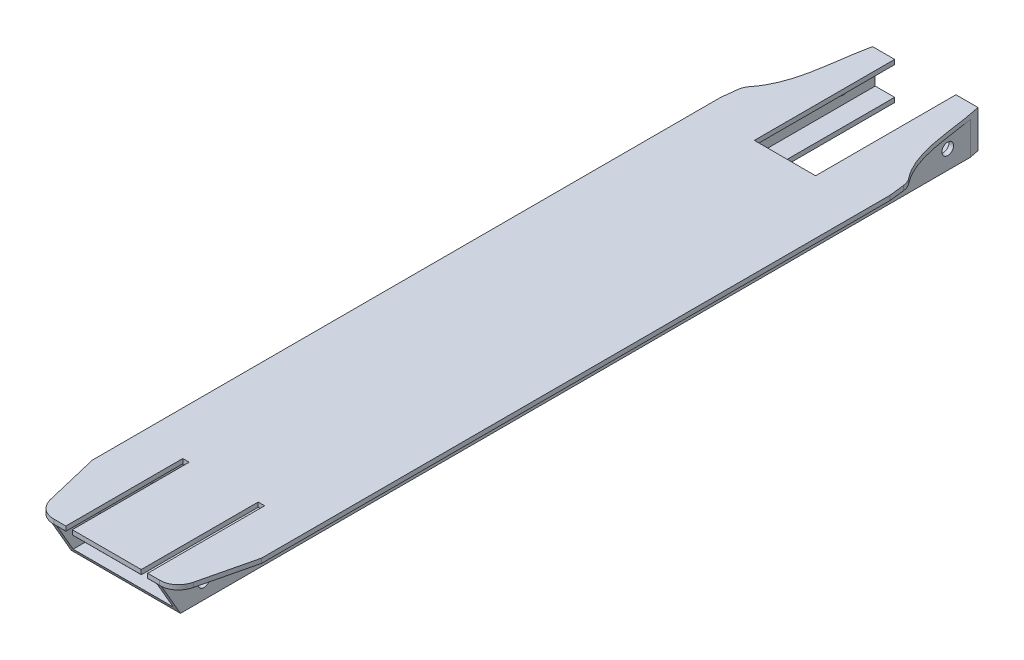
from build123d import *

# Parameters (mm, degrees)
SKETCH1_W               = 92.0242
SKETCH1_H               = 20.32
BOSS_EXTRUDE1_DEPTH     = 444.5
SKETCH2_W               = 54.356
SKETCH2_H               = 15.3416
SKETCH2_W_2             = 16.3449
SKETCH2_H_2             = 17.8308
CUT_EXTRUDE1_DEPTH      = 445.5
SKETCH3_W               = 33.274
SKETCH3_H               = 76.2
CUT_EXTRUDE2_DEPTH      = 21.32
SKETCH4_W               = 3.5052
SKETCH4_H               = 63.5
CUT_EXTRUDE3_DEPTH      = 12.7
CUT_EXTRUDE5_DEPTH      = 76.6793001
SKETCH6_R               = 3.175
CUT_EXTRUDE6_DEPTH      = 76.6793001
SKETCH7_R               = 1.764906423
CUT_EXTRUDE7_DEPTH      = 76.6793001
SKETCH9_R               = 3.175
CUT_EXTRUDE8_DEPTH      = 47.0121001
CUT_EXTRUDE8_DEPTH_BACK = 47.0121001


with BuildPart() as part:
    # Sketch1 → Boss-Extrude1 (new body)
    with BuildSketch(Plane.XY):
        with Locations((0, -10.16)):
            Rectangle(SKETCH1_W, SKETCH1_H)
    extrude(amount=-BOSS_EXTRUDE1_DEPTH)

    # Sketch2 → Cut-Extrude1 (cut, through all)
    with BuildSketch(Plane.XY):
        with Locations((0, -10.16)):
            Rectangle(SKETCH2_W, SKETCH2_H)
        with Locations((37.83965, -11.4046)):
            Rectangle(SKETCH2_W_2, SKETCH2_H_2)
        with Locations((-37.83965, -11.4046)):
            Rectangle(SKETCH2_W_2, SKETCH2_H_2)
    extrude(amount=-CUT_EXTRUDE1_DEPTH, mode=Mode.SUBTRACT)

    # Sketch3 → Cut-Extrude2 (cut, through all)
    with BuildSketch(Plane(origin=(0, 0, 0), x_dir=(1, 0, 0), z_dir=(0, 1, 0))):
        with BuildLine():
            Line((-46.0121, 0), (-28.575, 0))
            add(Edge.make_bspline(
                [(-28.575, 0), (-35.717859011, 0), (-38.245794082, 5.707856621), (-38.842625262, 8.197153509)],
                knots=[0, 0, 0, 0, 1, 1, 1, 1], degree=3))
            Line((-38.842625262, 8.197153509), (-46.0121, 38.1))
            Line((-46.0121, 38.1), (-46.0121, 0))
        make_face()
        with BuildLine():
            add(Edge.make_bspline(
                [(28.575, 0), (35.717859011, 0), (38.245794082, 5.707856621), (38.842625262, 8.197153509)],
                knots=[0, 0, 0, 0, 1, 1, 1, 1], degree=3))
            Line((28.575, 0), (46.0121, 0))
            Line((46.0121, 0), (46.0121, 38.1))
            Line((46.0121, 38.1), (38.842625262, 8.197153509))
        make_face()
        with BuildLine():
            Line((46.0121, 444.5), (28.6258, 444.5))
            add(Edge.make_bspline(
                [(28.6258, 444.5), (32.693382337, 426.337896511), (31.854875968, 406.755772808), (43.153705429, 392.326383256)],
                knots=[0, 0, 0, 0, 0.951264786, 0.951264786, 0.951264786, 0.951264786], degree=3))
            ThreePointArc((43.153705429, 392.326383256), (44.408270339, 390.171508327), (45.032534863, 387.757442695))
            Line((45.032534863, 387.757442695), (46.0121, 379.348138392))
            Line((46.0121, 379.348138392), (46.0121, 444.5))
        make_face()
        with Locations((0, 406.4)):
            Rectangle(SKETCH3_W, SKETCH3_H)
        with BuildLine():
            add(Edge.make_bspline(
                [(-28.6258, 444.5), (-32.693382337, 426.337896511), (-31.854875968, 406.755772808), (-43.153705429, 392.326383256)],
                knots=[0, 0, 0, 0, 0.951264786, 0.951264786, 0.951264786, 0.951264786], degree=3))
            Line((-28.6258, 444.5), (-46.0121, 444.5))
            Line((-46.0121, 444.5), (-46.0121, 379.348138392))
            Line((-46.0121, 379.348138392), (-45.032534863, 387.757442695))
            ThreePointArc((-45.032534863, 387.757442695), (-44.408270339, 390.171508327), (-43.153705429, 392.326383256))
        make_face()
    extrude(amount=-CUT_EXTRUDE2_DEPTH, mode=Mode.SUBTRACT)

    # Sketch4 → Cut-Extrude3 (cut)
    with BuildSketch(Plane(origin=(0, 0, 0), x_dir=(1, 0, 0), z_dir=(0, 1, 0))):
        with Locations((20.4724, 31.75)):
            Rectangle(SKETCH4_W, SKETCH4_H)
        with Locations((-20.4724, 31.75)):
            Rectangle(SKETCH4_W, SKETCH4_H)
    extrude(amount=-CUT_EXTRUDE3_DEPTH, mode=Mode.SUBTRACT)

    # Sketch5 → Cut-Extrude5 (cut, through all)
    with BuildSketch(Plane(origin=(29.6672, 0, 0), x_dir=(0, 0, -1), z_dir=(1, 0, 0))):
        Polygon((0.046334806, -2.4892), (-3.084672114, 2.933863065), (-3.084672114, -20.32), (0.046334806, -20.32), align=None)
        Polygon((10.340951986, -20.32), (0.046334806, -2.4892), (0.046334806, -20.32), align=None)
    extrude(amount=-CUT_EXTRUDE5_DEPTH, mode=Mode.SUBTRACT)

    # Sketch6 → Cut-Extrude6 (cut, through all)
    with BuildSketch(Plane(origin=(29.6672, 0, 0), x_dir=(0, 0, -1), z_dir=(1, 0, 0))):
        with Locations((23.09476437, -11.4046)):
            Circle(SKETCH6_R)
        with Locations((51.66976437, -11.4046)):
            Circle(SKETCH6_R)
    extrude(amount=-CUT_EXTRUDE6_DEPTH, mode=Mode.SUBTRACT)

    # Sketch7 → Cut-Extrude7 (cut, through all)
    with BuildSketch(Plane(origin=(29.6672, 0, 0), x_dir=(0, 0, -1), z_dir=(1, 0, 0))):
        with Locations((368.3, -6.418973604)):
            Circle(SKETCH7_R)
    extrude(amount=-CUT_EXTRUDE7_DEPTH, mode=Mode.SUBTRACT)

    # Sketch9 → Cut-Extrude8 (cut, two sides)
    with BuildSketch(Plane(origin=(0, 0, 0), x_dir=(0, 0, -1), z_dir=(1, 0, 0))) as cut_extrude8_sk:
        with Locations((427.0375, -10.16)):
            Circle(SKETCH9_R)
    extrude(amount=CUT_EXTRUDE8_DEPTH, mode=Mode.SUBTRACT)
    extrude(cut_extrude8_sk.sketch, amount=-CUT_EXTRUDE8_DEPTH_BACK, mode=Mode.SUBTRACT)


solid = part.part
